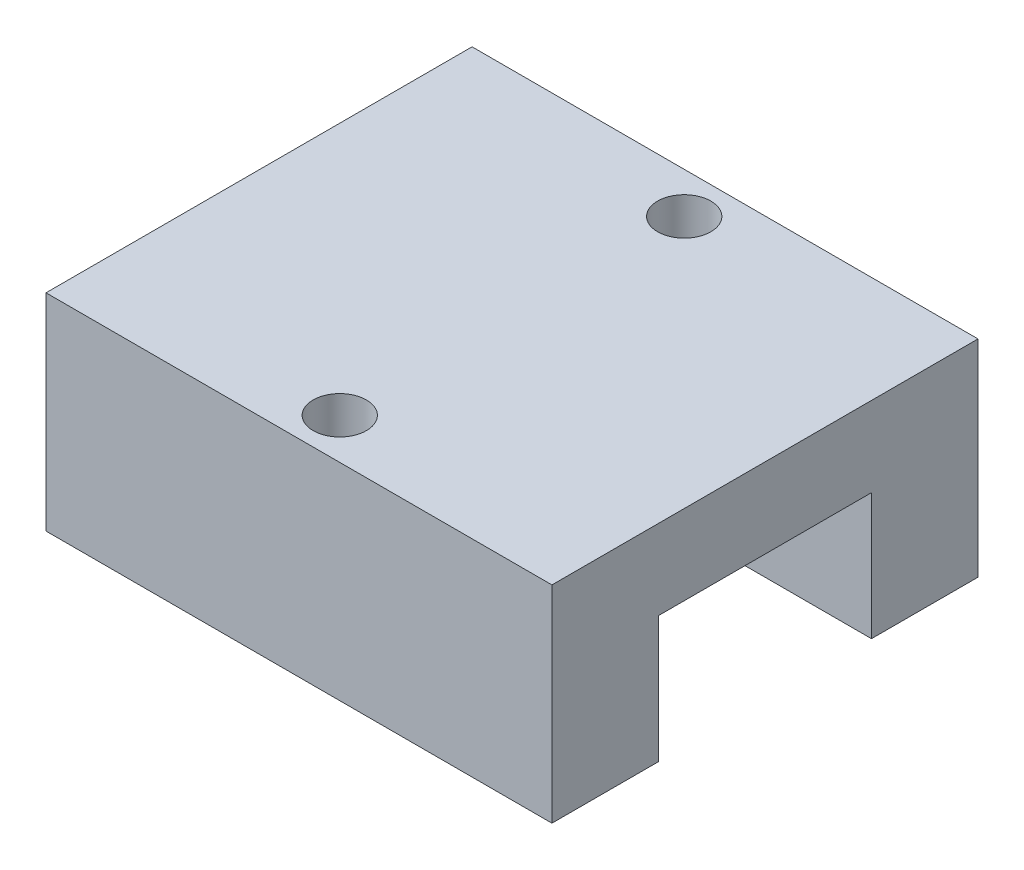
from build123d import *

# Parameters (mm, degrees)
SKETCH1_W          = 19
SKETCH1_H          = 16
EXTRUDE1_DEPTH     = 7.75
SKETCH2_R          = 1
CUT_EXTRUDE1_DEPTH = 17.75
SKETCH3_W          = 8
SKETCH3_H          = 4.75
CUT_EXTRUDE2_DEPTH = 27.75


with BuildPart() as part:
    # Sketch1 → Extrude1 (new body)
    with BuildSketch(Plane(origin=(0, 0, 0), x_dir=(1, 0, 0), z_dir=(0, 1, 0))):
        Rectangle(SKETCH1_W, SKETCH1_H)
    extrude(amount=EXTRUDE1_DEPTH)

    # Sketch2 → Cut-Extrude1 (cut)
    with BuildSketch(Plane.XZ):
        with Locations(Location((0, -6.4675, 0), (0, 0, 270))):  # turned: the seam where the file's is
            Circle(SKETCH2_R)
        with Locations(Location((0, 6.4675, 0), (0, 0, 270))):  # turned: the seam where the file's is
            Circle(SKETCH2_R)
    extrude(amount=-CUT_EXTRUDE1_DEPTH, mode=Mode.SUBTRACT)

    # Sketch3 → Cut-Extrude2 (cut)
    with BuildSketch(Plane(origin=(9.5, 0, 0), x_dir=(0, 0, -1), z_dir=(1, 0, 0))):
        with Locations((0, 2.375)):
            Rectangle(SKETCH3_W, SKETCH3_H)
    extrude(amount=-CUT_EXTRUDE2_DEPTH, mode=Mode.SUBTRACT)


solid = part.part
